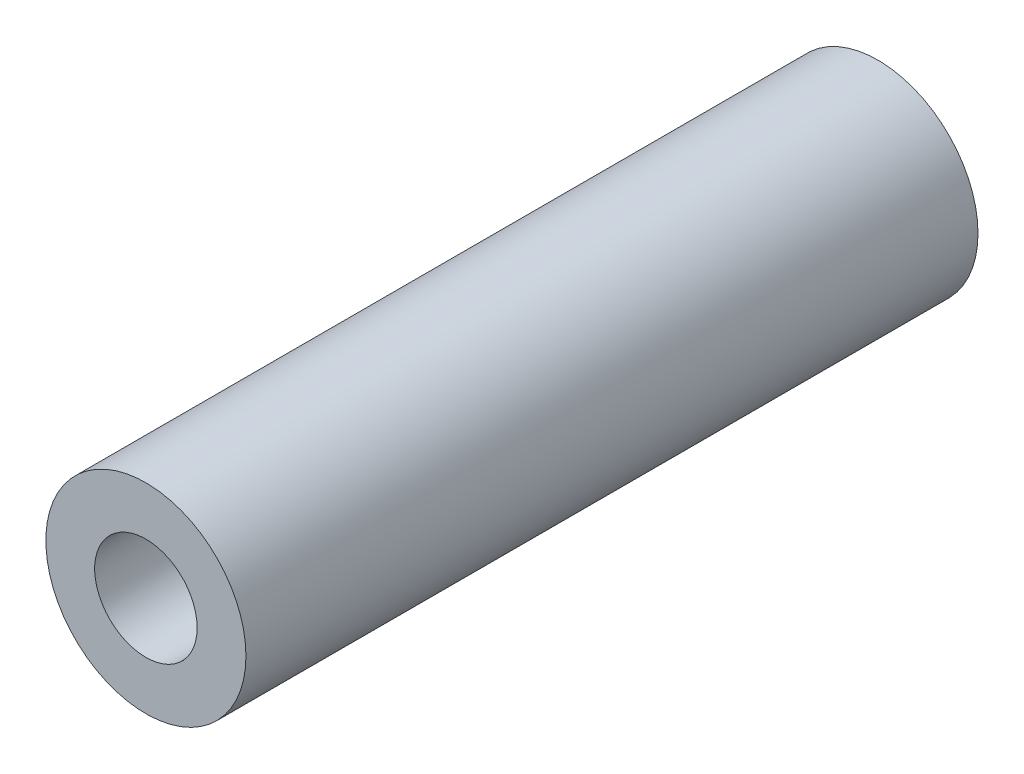
from build123d import *

# Parameters (mm, degrees)
SKETCH_1_R      = 4.1
SKETCH_1_R_2    = 2.1
EXTRUDE_1_DEPTH = 30


with BuildPart() as part:
    # ｽｹｯﾁ1 → ﾎﾞｽ - 押し出し1 (new body)
    with BuildSketch(Plane(origin=(0, 0, 0), x_dir=(0, 1, 0), z_dir=(0, 0, 1))):
        Circle(SKETCH_1_R)
        Circle(SKETCH_1_R_2, mode=Mode.SUBTRACT)
    extrude(amount=EXTRUDE_1_DEPTH)


solid = part.part
